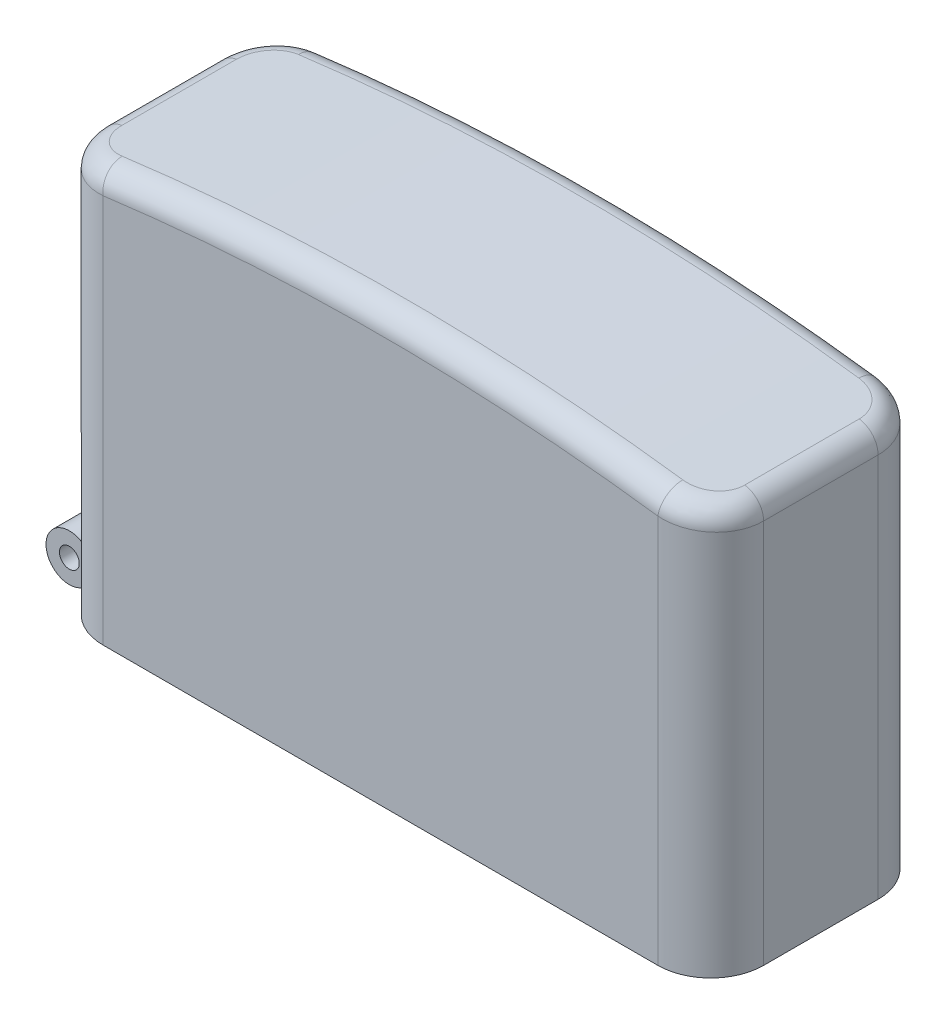
from build123d import *

# Parameters (mm, degrees)
BOSS_EXTRUDE1_DEPTH = 12.7
FILLET7_R           = 3.048
FILLET8_R           = 1.27
SHELL2_T            = -0.4572
SKETCH2_W           = 7.9502
SKETCH2_H           = 1.016
CUT_EXTRUDE1_DEPTH  = 11.7856
SKETCH4_W           = 1.3462
SKETCH4_H           = 1.5875
SKETCH5_R           = 0.5715
CUT_EXTRUDE2_DEPTH  = 11.3124001


with BuildPart() as part:
    # Sketch1 → Boss-Extrude1 (new body)
    with BuildSketch(Plane.XY):
        with BuildLine():
            Line((0, 0), (38.1, 0))
            Line((38.1, 0), (38.1, 23.2918))
            ThreePointArc((38.1, 23.2918), (19.05, 24.758348548), (0, 23.2918))
            Line((0, 23.2918), (0, 0))
        make_face()
    extrude(amount=BOSS_EXTRUDE1_DEPTH)

    # Fillet7
    fillet7_edges = [part.edges().sort_by_distance(p)[0] for p in [
        (38.1, 11.6459, 12.7),
        (0, 11.6459, 12.7),
        (38.1, 11.6459, 0),
        (0, 11.6459, 0),
    ]]
    fillet(fillet7_edges, radius=FILLET7_R)

    # Fillet8
    fillet8_edges = [part.edges().sort_by_distance(p)[0] for p in [
        (38.1, 23.2918, 6.35),
        (19.05, 24.758348548, 0),
        (0, 23.2918, 6.35),
        (19.05, 24.758348548, 12.7),
        (0.897565394, 23.427470684, 11.812077539),
        (0.897565394, 23.427470684, 0.887922461),
        (37.20243455, 23.427470691, 11.812077599),
        (37.20243455, 23.427470691, 0.887922401),
    ]]
    fillet(fillet8_edges, radius=FILLET8_R)

    # Shell2
    shell2_openings = [part.faces().sort_by_distance(p)[0] for p in [
        (19.05, 0, 6.35),
    ]]
    offset(amount=SHELL2_T, openings=shell2_openings, kind=Kind.INTERSECTION)

    # Sketch2 → Cut-Extrude1 (cut)
    with BuildSketch(Plane.ZY):
        with Locations((6.35, 0.508)):
            Rectangle(SKETCH2_W, SKETCH2_H)
    extrude(amount=-CUT_EXTRUDE1_DEPTH, mode=Mode.SUBTRACT)

    # Sketch4 → Revolve1 (revolve)
    with BuildSketch(Plane.XZ.offset(-1.016)):
        with Locations((-0.597849635, 6.35635)):
            Rectangle(SKETCH4_W, SKETCH4_H)
        with Locations((-0.597849635, 9.53135)):
            Rectangle(SKETCH4_W, SKETCH4_H)
        with Locations((-0.597849635, 3.18135)):
            Rectangle(SKETCH4_W, SKETCH4_H)
    revolve(axis=Axis((-1.270949635, 1.016, 10.3251), (0, 0, -1)))

    # Sketch5 → Cut-Extrude2 (cut, through all)
    with BuildSketch(Plane(origin=(0, 0, 2.3876), x_dir=(-1, 0, 0), z_dir=(0, 0, -1))):
        with Locations((1.270949635, 1.016)):
            Circle(SKETCH5_R)
    extrude(amount=-CUT_EXTRUDE2_DEPTH, mode=Mode.SUBTRACT)


solid = part.part
